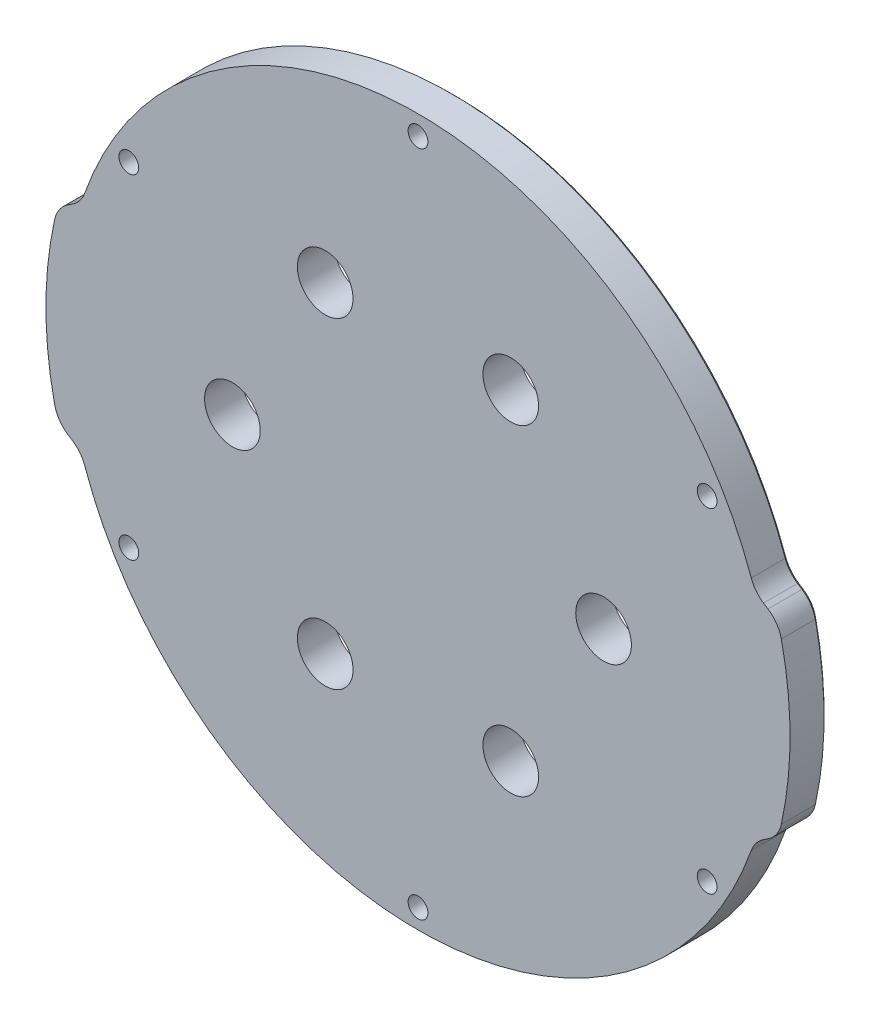
from build123d import *

# Parameters (mm, degrees)
EXTRUDE_1_DEPTH             = 6
CUT_EXTRUDE_1_DEPTH         = 7
HOLE_WIZARD_9_0_9_1_D       = 9
HOLE_WIZARD_9_0_9_1_DEPTH   = 6
HOLE_WIZARD_3_2_3_2_1_D     = 3.2
HOLE_WIZARD_3_2_3_2_1_DEPTH = 6
FILLET_1_R                  = 5
CHAMFER_1_SIZE              = 0.5


with BuildPart() as part:
    # 草图1 → 凸台-拉伸1 (new body)
    with BuildSketch(Plane.XY.offset(6)):
        with BuildLine():
            Line((-54.404710274, 17.5), (-58.249656651, 15))
            ThreePointArc((-58.249656651, 15), (0, -60.15), (58.249656651, 15))
            Line((58.249656651, 15), (54.404710274, 17.5))
            ThreePointArc((54.404710274, 17.5), (0, 57.15), (-54.404710274, 17.5))
        make_face()
    extrude(amount=-EXTRUDE_1_DEPTH)

    # 草图2 → 切除-拉伸1 (cut, through all)
    with BuildSketch(Plane(origin=(0, 0, 0), x_dir=(-1, 0, 0), z_dir=(0, 0, -1))):
        with BuildLine():
            Line((58.249656651, -15), (54.404710274, -17.5))
            ThreePointArc((54.404710274, -17.5), (0, -57.15), (-54.404710274, -17.5))
            Line((-54.404710274, -17.5), (-58.249656651, -15))
            ThreePointArc((-58.249656651, -15), (0, -60.15), (58.249656651, -15))
        make_face()
    extrude(amount=-CUT_EXTRUDE_1_DEPTH, mode=Mode.SUBTRACT)

    # Ø9.0 (9) 直径孔1
    with Locations(Plane(origin=(0, 0, 0), x_dir=(-1, 0, 0), z_dir=(0, 0, -1))):
        with Locations((-15, 25.980762114), (15, 25.980762114), (30, 0), (15, -25.980762114), (-15, -25.980762114), (-30, 0)):
            Hole(HOLE_WIZARD_9_0_9_1_D / 2, depth=HOLE_WIZARD_9_0_9_1_DEPTH)

    # Ø3.2 (3.2) 直径孔1
    with Locations(Plane(origin=(0, 0, 0), x_dir=(-1, 0, 0), z_dir=(0, 0, -1))):
        with Locations((0, 53.975), (46.743721169, -26.9875), (-46.743721169, 26.9875), (-46.743721169, -26.9875), (0, -53.975), (46.743721169, 26.9875)):
            Hole(HOLE_WIZARD_3_2_3_2_1_D / 2, depth=HOLE_WIZARD_3_2_3_2_1_DEPTH)

    # 圆角1
    fillet_1_edges = [part.edges().sort_by_distance(p)[0] for p in [
        (-58.249656651, -15, 3),
        (58.249656651, -15, 3),
        (54.404710274, -17.5, 3),
        (-54.404710274, -17.5, 3),
        (54.404710274, 17.5, 3),
        (58.249656651, 15, 3),
        (-58.249656651, 15, 3),
        (-54.404710274, 17.5, 3),
    ]]
    fillet(fillet_1_edges, radius=FILLET_1_R)

    # 倒角1
    chamfer_1_edges = [part.edges().sort_by_distance(p)[0] for p in [
        (60.15, 0, 0),
        (56.218559502, 16.320627747, 0),
        (56.218559502, -16.320627747, 0),
        (-60.15, 0, 0),
        (-56.218559502, 16.320627747, 0),
        (0, 57.15, 0),
        (-57.961950962, 14.742761538, 0),
        (57.961950962, -14.742761538, 0),
        (-57.961950962, -14.742761538, 0),
        (57.961950962, 14.742761538, 0),
        (-54.657828511, -17.651398409, 0),
        (54.657828511, -17.651398409, 0),
        (54.657828511, 17.651398409, 0),
        (-54.657828511, 17.651398409, 0),
        (0, -57.15, 0),
        (-56.218559502, -16.320627747, 0),
    ]]
    chamfer(chamfer_1_edges, length=CHAMFER_1_SIZE)


solid = part.part
